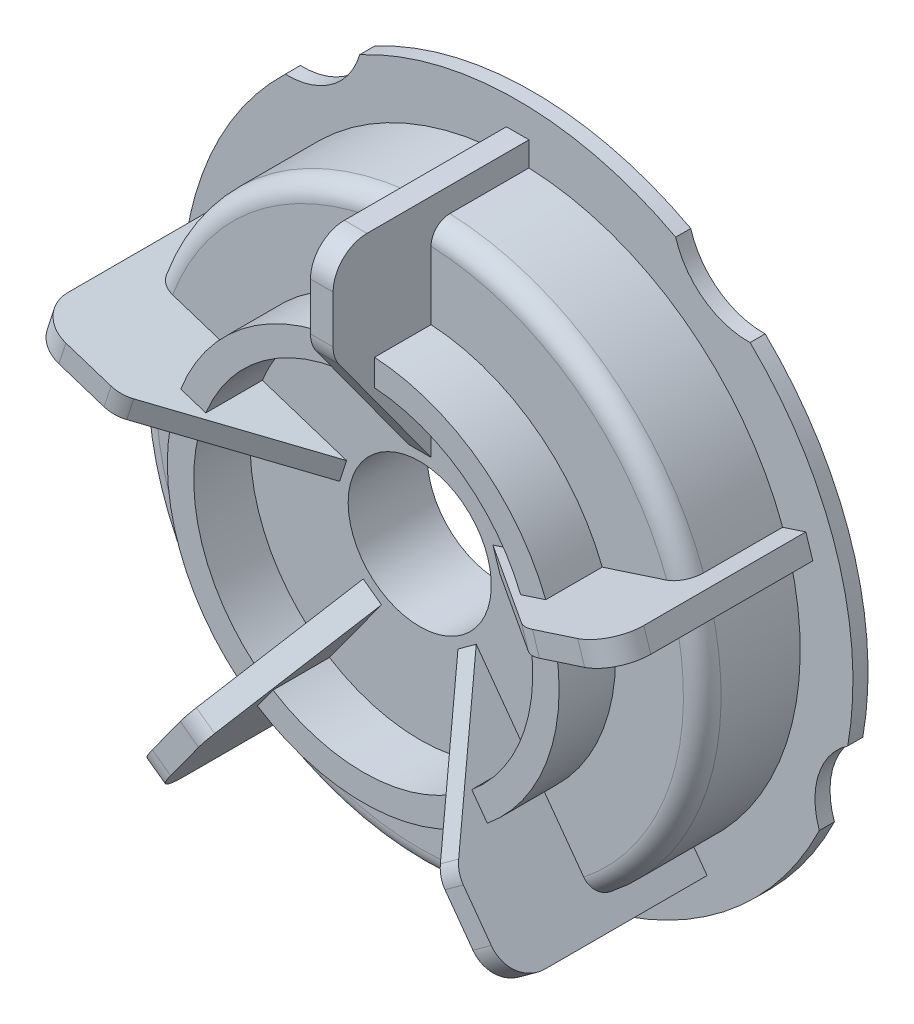
from build123d import *

# Parameters (mm, degrees)
FILLET1_R                = 2.5
BOSS_EXTRUDE1_DEPTH      = 1.5
FILLET2_R                = 4
CIRPATTERN1_COUNT        = 5
FILLET2_OF_CIRPATTERN1_R = 4
CUT_EXTRUDE1_START       = -29.0000001
SKETCH4_R                = 10
CUT_EXTRUDE1_DEPTH       = 30.0000001
BOSS_EXTRUDE2_DEPTH      = 12
SKETCH6_W                = 1.75
SKETCH6_H                = 24
BOSS_EXTRUDE3_DEPTH      = 8.5
CIRPATTERN2_COUNT        = 5


with BuildPart() as part:
    # Sketch2 → Revolve1 (revolve)
    with BuildSketch(Plane(origin=(0, 0, 0), x_dir=(0, 0, -1), z_dir=(1, 0, 0))):
        Polygon((2.5, 44.5), (2.5, 37.5), (-10.5, 37.5), (-10.5, 26), (-18, 26), (-18, 22.5), (-10.5, 22.5), (-10.5, 9.5), (0, 9.5), (0, 11.5), (-8.5, 11.5), (-8.5, 35.5), (4.5, 35.5), (4.5, 44.5), align=None)
    revolve(axis=Axis((0, 0, -45.438153482), (0, 0, 1)))

    # Fillet1
    fillet1_edges = [part.edges().sort_by_distance(p)[0] for p in [
        (0, -37.5, 10.5),
    ]]
    fillet(fillet1_edges, radius=FILLET1_R)

    # Sketch3 → Boss-Extrude1 (add, symmetric)
    with BuildSketch(Plane(origin=(0, 0, 0), x_dir=(0, 0, -1), z_dir=(1, 0, 0))):
        with BuildLine():
            Line((2.5, 40.7), (-19, 40.7))
            ThreePointArc((-19, 40.7), (-22.181980515, 39.381980515), (-23.5, 36.2))
            Line((-23.5, 36.2), (-23.5, 28.592964966))
            Line((-23.5, 28.592964966), (-10.5, 10.7))
            Line((-10.5, 10.7), (-10.5, 33.460767767))
            Line((-10.5, 33.460767767), (-6.918763004, 36.95))
            Line((-6.918763004, 36.95), (2.5, 36.95))
            Line((2.5, 36.95), (2.5, 40.7))
        make_face()
    boss_extrude1 = extrude(amount=BOSS_EXTRUDE1_DEPTH, both=True)

    # Fillet2
    fillet2_edges = [part.edges().sort_by_distance(p)[0] for p in [
        (0, 28.592964966, 23.5),
    ]]
    fillet(fillet2_edges, radius=FILLET2_R)

    # CirPattern1: Boss-Extrude1 ×5 about axis
    cirpattern1_axis = Axis((0, 0, 0), (0, 0, 1))
    for i in range(1, CIRPATTERN1_COUNT):
        add(boss_extrude1.rotate(cirpattern1_axis, i * 360 / CIRPATTERN1_COUNT))

    # Fillet2 of CirPattern1
    fillet2_of_cirpattern1_edges = [part.edges().sort_by_distance(p)[0] for p in [
        (-27.193525651, 8.835712094, 23.5),
        (-16.806523126, -23.132194577, 23.5),
        (16.806523126, -23.132194577, 23.5),
        (27.193525651, 8.835712094, 23.5),
    ]]
    fillet(fillet2_of_cirpattern1_edges, radius=FILLET2_OF_CIRPATTERN1_R)

    # Sketch4 → Cut-Extrude1 (cut)
    with BuildSketch(Plane(origin=(0, 0, -4.5), x_dir=(-1, 0, 0), z_dir=(0, 0, -1)).offset(CUT_EXTRUDE1_START)):
        with Locations((0, -52)):
            Circle(SKETCH4_R)
    cut_extrude1 = extrude(amount=CUT_EXTRUDE1_DEPTH, mode=Mode.SUBTRACT)

    # Sketch5 → Boss-Extrude2 (add)
    with BuildSketch(Plane(origin=(0, 0, 8.5), x_dir=(-1, 0, 0), z_dir=(0, 0, -1))):
        with BuildLine():
            Line((-2.997320764, -35.373239437), (0, -37.103743386))
            Line((0, -37.103743386), (2.997320764, -35.373239437))
            ThreePointArc((2.997320764, -35.373239437), (0, -32.5), (-2.997320764, -35.373239437))
        make_face()
    boss_extrude2 = extrude(amount=BOSS_EXTRUDE2_DEPTH)

    # Sketch6 → Boss-Extrude3 (add)
    with BuildSketch(Plane(origin=(0, 0, 8.5), x_dir=(-1, 0, 0), z_dir=(0, 0, -1))):
        with Locations((0, -22.75)):
            Rectangle(SKETCH6_W, SKETCH6_H)
    boss_extrude3 = extrude(amount=BOSS_EXTRUDE3_DEPTH)

    # CirPattern2: Cut-Extrude1, Boss-Extrude2, Boss-Extrude3 ×5 about axis
    cirpattern2_axis = Axis((0, 0, 0), (0, 0, 1))
    for i in range(1, CIRPATTERN2_COUNT):
        add(cut_extrude1.rotate(cirpattern2_axis, i * 360 / CIRPATTERN2_COUNT), mode=Mode.SUBTRACT)
        add(boss_extrude2.rotate(cirpattern2_axis, i * 360 / CIRPATTERN2_COUNT))
        add(boss_extrude3.rotate(cirpattern2_axis, i * 360 / CIRPATTERN2_COUNT))


solid = part.part
